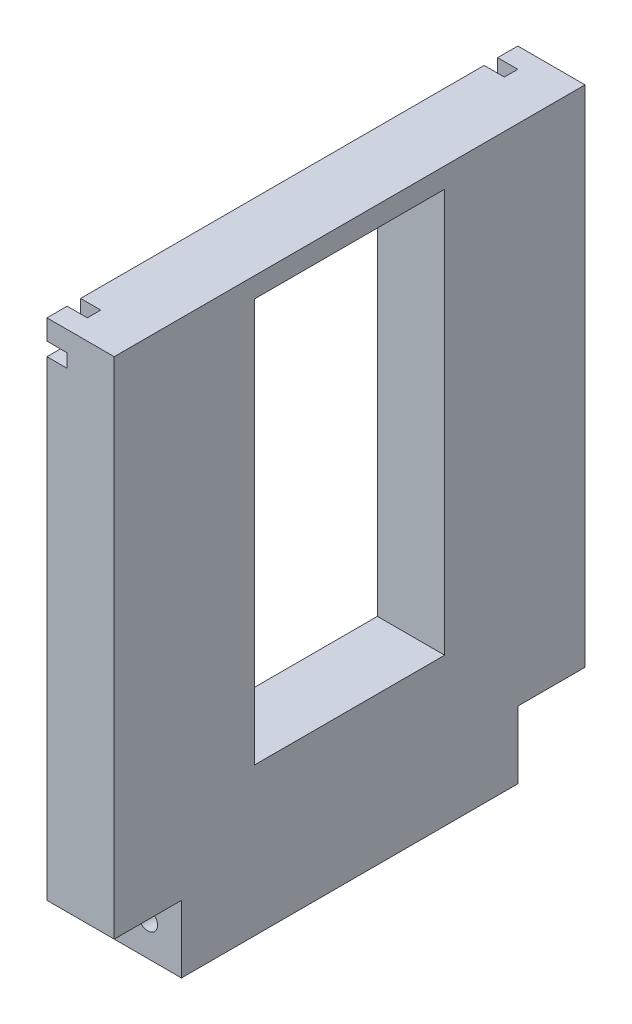
from build123d import *

# Parameters (mm, degrees)
CROQUIS1_W              = 10
CROQUIS1_H              = 70
SALIENTE_EXTRUIR1_DEPTH = 10
CROQUIS8_W              = 10
CROQUIS8_H              = 70
SALIENTE_EXTRUIR3_DEPTH = 75
CROQUIS9_W              = 2
CROQUIS9_H              = 75
CORTAR_EXTRUIR4_DEPTH   = 3
CROQUIS10_W             = 70
CROQUIS10_H             = 2
CORTAR_EXTRUIR5_DEPTH   = 3
CORTAR_EXTRUIR6_REACH   = 12
CROQUIS11_W             = 28.25
CROQUIS11_H             = 60
CROQUIS16_W             = 10
CROQUIS16_H             = 5
SALIENTE_EXTRUIR5_DEPTH = 7
CROQUIS17_R             = 1.435
CORTAR_EXTRUIR9_DEPTH   = 5
CROQUIS18_W             = 10
CROQUIS18_H             = 10
CORTAR_EXTRUIR10_DEPTH  = 10
CROQUIS19_R             = 1.435
CORTAR_EXTRUIR11_DEPTH  = 10


with BuildPart() as part:
    # Croquis1 → Saliente-Extruir1 (new body)
    with BuildSketch(Plane(origin=(0, 0, 0), x_dir=(1, 0, 0), z_dir=(0, 1, 0))):
        Rectangle(CROQUIS1_W, CROQUIS1_H)
    extrude(amount=SALIENTE_EXTRUIR1_DEPTH)

    # Croquis8 → Saliente-Extruir3 (add)
    with BuildSketch(Plane(origin=(0, 10, 0), x_dir=(1, 0, 0), z_dir=(0, 1, 0))):
        Rectangle(CROQUIS8_W, CROQUIS8_H)
    extrude(amount=SALIENTE_EXTRUIR3_DEPTH)

    # Croquis9 → Cortar-Extruir4 (cut)
    with BuildSketch(Plane.ZY.offset(5)):
        with Locations((-31, 47.5)):
            Rectangle(CROQUIS9_W, CROQUIS9_H)
    cortar_extruir4 = extrude(amount=-CORTAR_EXTRUIR4_DEPTH, mode=Mode.SUBTRACT)

    # Simetría2: Cortar-Extruir4 across plane
    add(cortar_extruir4.mirror(Plane.XY), mode=Mode.SUBTRACT)

    # Croquis10 → Cortar-Extruir5 (cut)
    with BuildSketch(Plane.ZY.offset(5)):
        with Locations((0, 81)):
            Rectangle(CROQUIS10_W, CROQUIS10_H)
    extrude(amount=-CORTAR_EXTRUIR5_DEPTH, mode=Mode.SUBTRACT)

    # Croquis11 → Cortar-Extruir6 (cut, up to next)
    with BuildSketch(Plane.ZY.offset(5), mode=Mode.PRIVATE) as cortar_extruir6_sk1:
        with Locations((0, 52)):
            Rectangle(CROQUIS11_W, CROQUIS11_H)
    cortar_extruir6_tool1 = extrude(cortar_extruir6_sk1.sketch, amount=-CORTAR_EXTRUIR6_REACH, mode=Mode.PRIVATE) & part.part
    add(cortar_extruir6_tool1.solids().sort_by_distance((-5, 52, 0))[0], mode=Mode.SUBTRACT)

    # Croquis16 → Saliente-Extruir5 (add)
    with BuildSketch(Plane.ZY.offset(5)):
        with Locations((-15, 12.5)):
            Rectangle(CROQUIS16_W, CROQUIS16_H)
    saliente_extruir5 = extrude(amount=SALIENTE_EXTRUIR5_DEPTH)

    # Simetría5: Saliente-Extruir5 across plane
    add(saliente_extruir5.mirror(Plane.XY))

    # Croquis17 → Cortar-Extruir9 (cut)
    with BuildSketch(Plane(origin=(0, 15, 0), x_dir=(1, 0, 0), z_dir=(0, 1, 0))):
        with Locations((-8.5, 15)):
            Circle(CROQUIS17_R)
    cortar_extruir9 = extrude(amount=-CORTAR_EXTRUIR9_DEPTH, mode=Mode.SUBTRACT)

    # Simetría6: Cortar-Extruir9 across plane
    add(cortar_extruir9.mirror(Plane.XY), mode=Mode.SUBTRACT)

    # Croquis18 → Cortar-Extruir10 (cut)
    with BuildSketch(Plane.ZY.offset(5)):
        with Locations((-30, 5)):
            Rectangle(CROQUIS18_W, CROQUIS18_H)
    cortar_extruir10 = extrude(amount=-CORTAR_EXTRUIR10_DEPTH, mode=Mode.SUBTRACT)

    # Simetría7: Cortar-Extruir10 across plane
    add(cortar_extruir10.mirror(Plane.XY), mode=Mode.SUBTRACT)

    # Croquis19 → Cortar-Extruir11 (cut)
    with BuildSketch(Plane(origin=(0, 0, -25), x_dir=(-1, 0, 0), z_dir=(0, 0, -1))):
        with Locations((0, 5)):
            Circle(CROQUIS19_R)
    cortar_extruir11 = extrude(amount=-CORTAR_EXTRUIR11_DEPTH, mode=Mode.SUBTRACT)

    # Simetría8: Cortar-Extruir11 across plane
    add(cortar_extruir11.mirror(Plane.XY), mode=Mode.SUBTRACT)


solid = part.part
